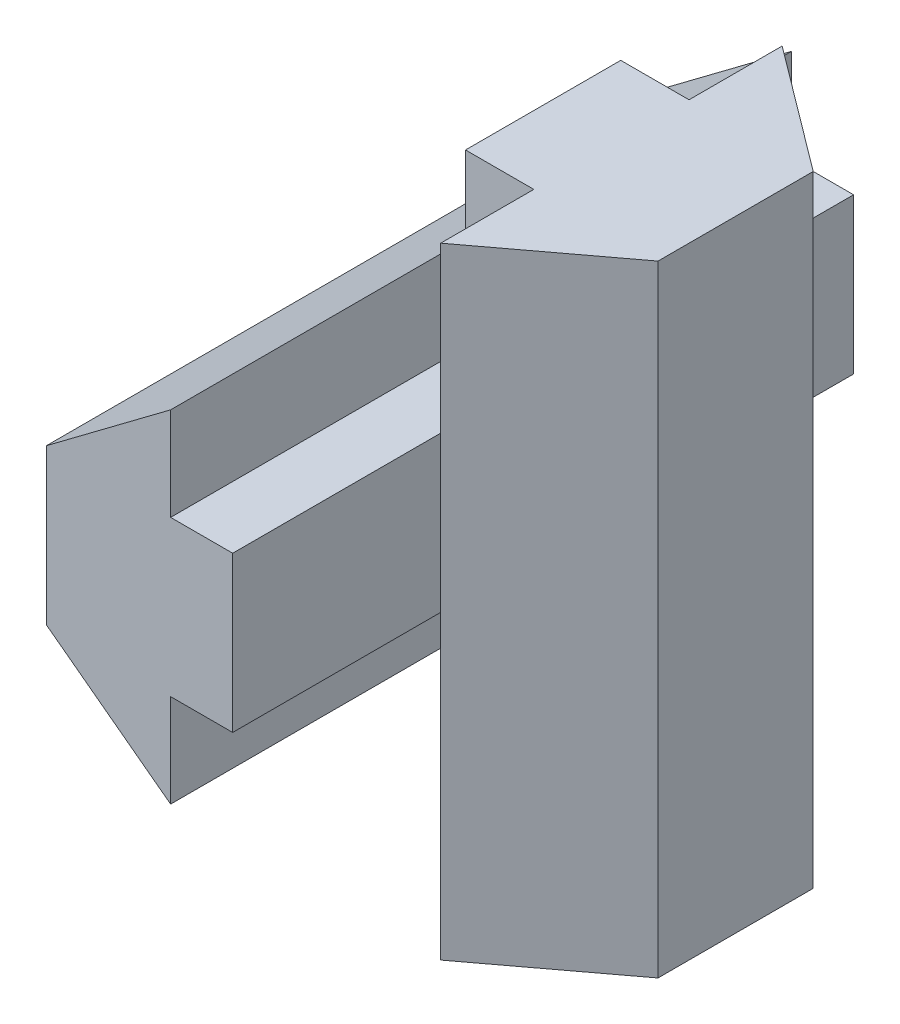
from build123d import *

# Parameters (mm, degrees)
BOSS_EXTRU_1_DEPTH = 10
BOSS_EXTRU_2_DEPTH = 10


with BuildPart() as part:
    # ProfileRainureEsquisse → Boss.-Extru.1 (new body, symmetric)
    with BuildSketch(Plane.XY):
        Polygon((0, -2.5), (0, 2.5), (4, 5.5), (4, 2.5), (6, 2.5), (6, -2.5), (4, -2.5), (4, -5.5), align=None)
    extrude(amount=BOSS_EXTRU_1_DEPTH, both=True)

    # Esquisse1 → Boss.-Extru.2 (add, symmetric)
    with BuildSketch(Plane(origin=(0, 0, 0), x_dir=(1, 0, 0), z_dir=(0, 1, 0))):
        Polygon((6, 2.5), (8.2, 2.5), (8.2, 5.5), (12.2, 2.5), (12.2, -2.5), (8.2, -5.5), (8.2, -2.5), (6, -2.5), align=None)
    extrude(amount=BOSS_EXTRU_2_DEPTH, both=True)


solid = part.part
